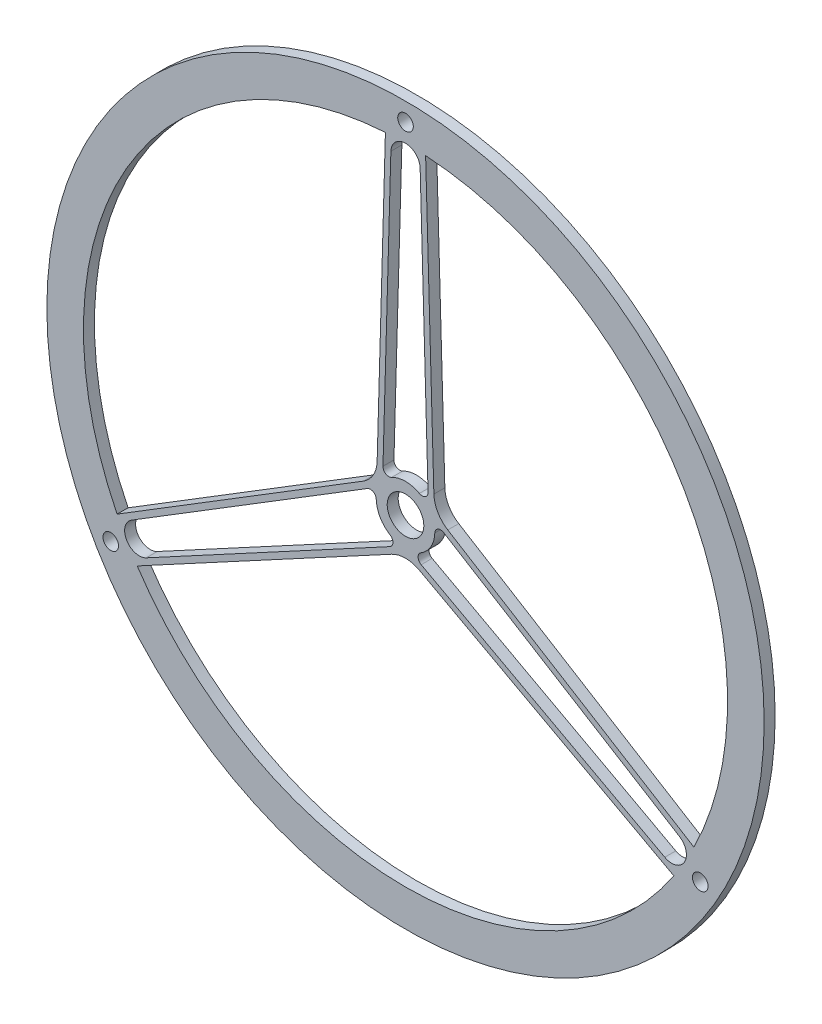
from build123d import *

# Parameters (mm, degrees)
SKETCH1_R                = 155.575
SKETCH1_R_2              = 7.9375
BOSS_EXTRUDE1_DEPTH      = 4.7625
FILLET1_R                = 12.7
FILLET4_R                = 2.54
H_0_266_DIAMETER_HOLE1_D = 6.7564


with BuildPart() as part:
    # Sketch1 → Boss-Extrude1 (new body)
    with BuildSketch(Plane.XY):
        Circle(SKETCH1_R)
        with BuildLine():
            ThreePointArc((-125.107792883, -62.16212802), (-120.983748909, 69.85), (-8.719914422, 139.427590858))
            Line((-8.719914422, 139.427590858), (-12.49892387, 7.216257061))
            Line((-12.49892387, 7.216257061), (-125.107792883, -62.16212802))
        make_face(mode=Mode.SUBTRACT)
        with BuildLine():
            ThreePointArc((8.719914422, 139.427590858), (120.983748909, 69.85), (125.107792883, -62.16212802))
            Line((125.107792883, -62.16212802), (12.49892387, 7.216257061))
            Line((12.49892387, 7.216257061), (8.719914422, 139.427590858))
        make_face(mode=Mode.SUBTRACT)
        with BuildLine():
            ThreePointArc((116.38787846, -77.265462838), (0, -139.7), (-116.38787846, -77.265462838))
            Line((-116.38787846, -77.265462838), (0, -14.432514122))
            Line((0, -14.432514122), (116.38787846, -77.265462838))
        make_face(mode=Mode.SUBTRACT)
        with BuildLine():
            Line((-12.585726429, 4.179407795), (-12.694815268, 0.362857143))
            ThreePointArc((-12.694815268, 0.362857143), (-10.998522628, -6.35), (-6.03316413, -11.17546109))
            Line((-6.03316413, -11.17546109), (-2.673389891, -12.98926271))
            Line((-2.673389891, -12.98926271), (-112.467905529, -72.262730545))
            ThreePointArc((-112.467905529, -72.262730545), (-120.983748909, -69.85), (-118.815313164, -61.268698026))
            Line((-118.815313164, -61.268698026), (-12.585726429, 4.179407795))
        make_face(mode=Mode.SUBTRACT)
        with BuildLine():
            ThreePointArc((118.815313164, -61.268698026), (120.983748909, -69.85), (112.467905529, -72.262730545))
            Line((112.467905529, -72.262730545), (2.673389891, -12.98926271))
            Line((2.673389891, -12.98926271), (6.03316413, -11.17546109))
            ThreePointArc((6.03316413, -11.17546109), (10.998522628, -6.35), (12.694815268, 0.362857143))
            Line((12.694815268, 0.362857143), (12.585726429, 4.179407795))
            Line((12.585726429, 4.179407795), (118.815313164, -61.268698026))
        make_face(mode=Mode.SUBTRACT)
        Circle(SKETCH1_R_2, mode=Mode.SUBTRACT)
        with BuildLine():
            ThreePointArc((-6.347407634, 133.531428571), (0, 139.7), (6.347407634, 133.531428571))
            Line((6.347407634, 133.531428571), (9.938137929, 7.907174875))
            ThreePointArc((9.938137929, 7.907174875), (0, 12.7), (-9.938137929, 7.907174875))
            Line((-9.938137929, 7.907174875), (-6.347407634, 133.531428571))
        make_face(mode=Mode.SUBTRACT)
    extrude(amount=-BOSS_EXTRUDE1_DEPTH)

    # Fillet1
    fillet1_edges = [part.edges().sort_by_distance(p)[0] for p in [
        (12.49892387, 7.216257061, -2.38125),
        (0, -14.432514122, -2.38125),
        (-12.49892387, 7.216257061, -2.38125),
    ]]
    fillet(fillet1_edges, radius=FILLET1_R)

    # Fillet4
    fillet4_edges = [part.edges().sort_by_distance(p)[0] for p in [
        (12.585726429, 4.179407795, -2.38125),
        (2.673389891, -12.98926271, -2.38125),
        (-2.673389891, -12.98926271, -2.38125),
        (-12.585726429, 4.179407795, -2.38125),
        (-9.938137929, 7.907174875, -2.38125),
        (9.938137929, 7.907174875, -2.38125),
    ]]
    fillet(fillet4_edges, radius=FILLET4_R)

    # H (0.266) Diameter Hole1 (through all)
    with Locations(Plane.XY):
        with Locations((0, 147.6375), (127.857825551, -73.81875), (-127.857825551, -73.81875)):
            Hole(H_0_266_DIAMETER_HOLE1_D / 2)


solid = part.part
